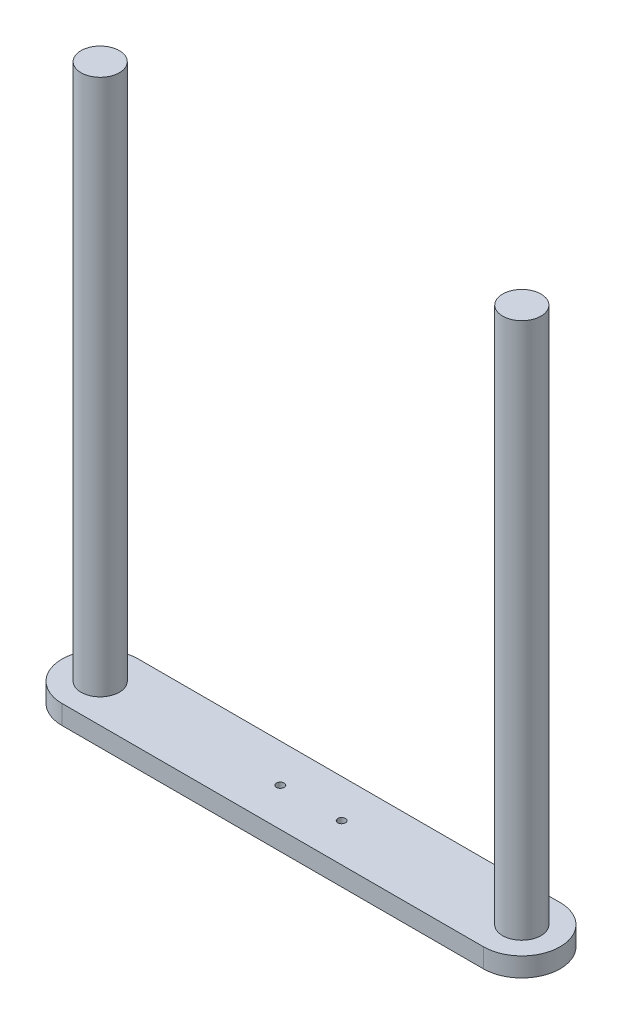
from build123d import *

# Parameters (mm, degrees)
SKETCH1_W           = 139.7
SKETCH1_H           = 25.4
BOSS_EXTRUDE1_DEPTH = 6.35
SKETCH2_R           = 6.35
BOSS_EXTRUDE2_DEPTH = 177.8
SKETCH3_R           = 1.27
CUT_EXTRUDE1_DEPTH  = 7.35


with BuildPart() as part:
    # Sketch1 → Boss-Extrude1 (new body)
    with BuildSketch(Plane(origin=(0, 0, 0), x_dir=(1, 0, 0), z_dir=(0, 1, 0))):
        with BuildLine():
            Line((-69.85, 12.7), (-69.85, -12.7))
            ThreePointArc((-69.85, -12.7), (-82.55, 0), (-69.85, 12.7))
        make_face()
        with BuildLine():
            ThreePointArc((69.85, 12.7), (82.55, 0), (69.85, -12.7))
            Line((69.85, -12.7), (69.85, 12.7))
        make_face()
        Rectangle(SKETCH1_W, SKETCH1_H)
    extrude(amount=BOSS_EXTRUDE1_DEPTH)

    # Sketch2 → Boss-Extrude2 (add)
    with BuildSketch(Plane(origin=(0, 6.35, 0), x_dir=(1, 0, 0), z_dir=(0, 1, 0))):
        with Locations((-69.85, 0)):
            Circle(SKETCH2_R)
        with Locations((69.85, 0)):
            Circle(SKETCH2_R)
    extrude(amount=BOSS_EXTRUDE2_DEPTH)

    # Sketch3 → Cut-Extrude1 (cut, through all)
    with BuildSketch(Plane(origin=(0, 6.35, 0), x_dir=(1, 0, 0), z_dir=(0, 1, 0))):
        with Locations((-10.16, 0)):
            Circle(SKETCH3_R)
        with Locations((10.16, 0)):
            Circle(SKETCH3_R)
    extrude(amount=-CUT_EXTRUDE1_DEPTH, mode=Mode.SUBTRACT)


solid = part.part
